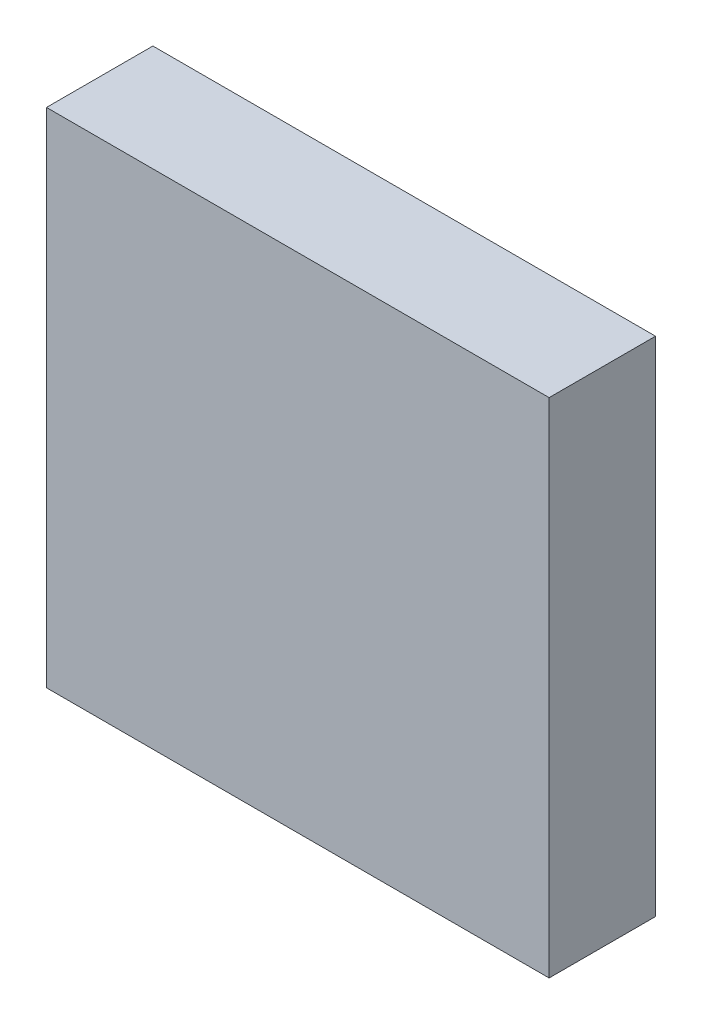
from build123d import *

# Parameters (mm, degrees)
SKETCH1_W           = 30
SKETCH1_H           = 30
BOSS_EXTRUDE1_DEPTH = 6.35


with BuildPart() as part:
    # Sketch1 → Boss-Extrude1 (new body)
    with BuildSketch(Plane.XY):
        with Locations((15, 15)):
            Rectangle(SKETCH1_W, SKETCH1_H)
    extrude(amount=BOSS_EXTRUDE1_DEPTH)


solid = part.part
